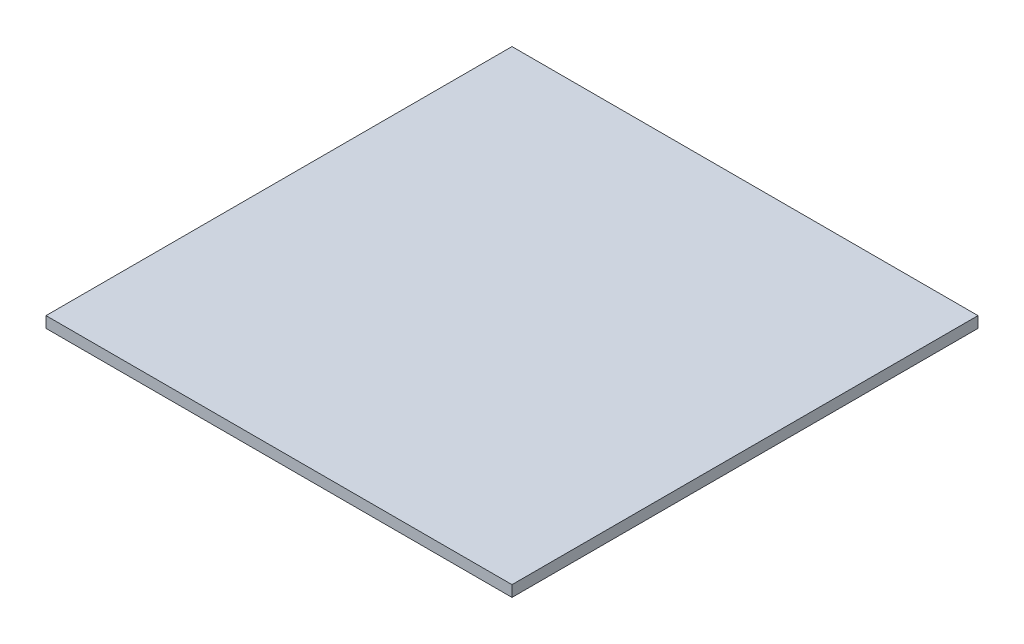
from build123d import *

# Parameters (mm, degrees)
ESQUISSE1_W        = 420
ESQUISSE1_H        = 420
BOSS_EXTRU_1_DEPTH = 10


with BuildPart() as part:
    # Esquisse1 → Boss.-Extru.1 (new body)
    with BuildSketch(Plane(origin=(0, 0, 0), x_dir=(1, 0, 0), z_dir=(0, 1, 0))):
        with Locations((210, 210)):
            Rectangle(ESQUISSE1_W, ESQUISSE1_H)
    extrude(amount=BOSS_EXTRU_1_DEPTH)


solid = part.part
